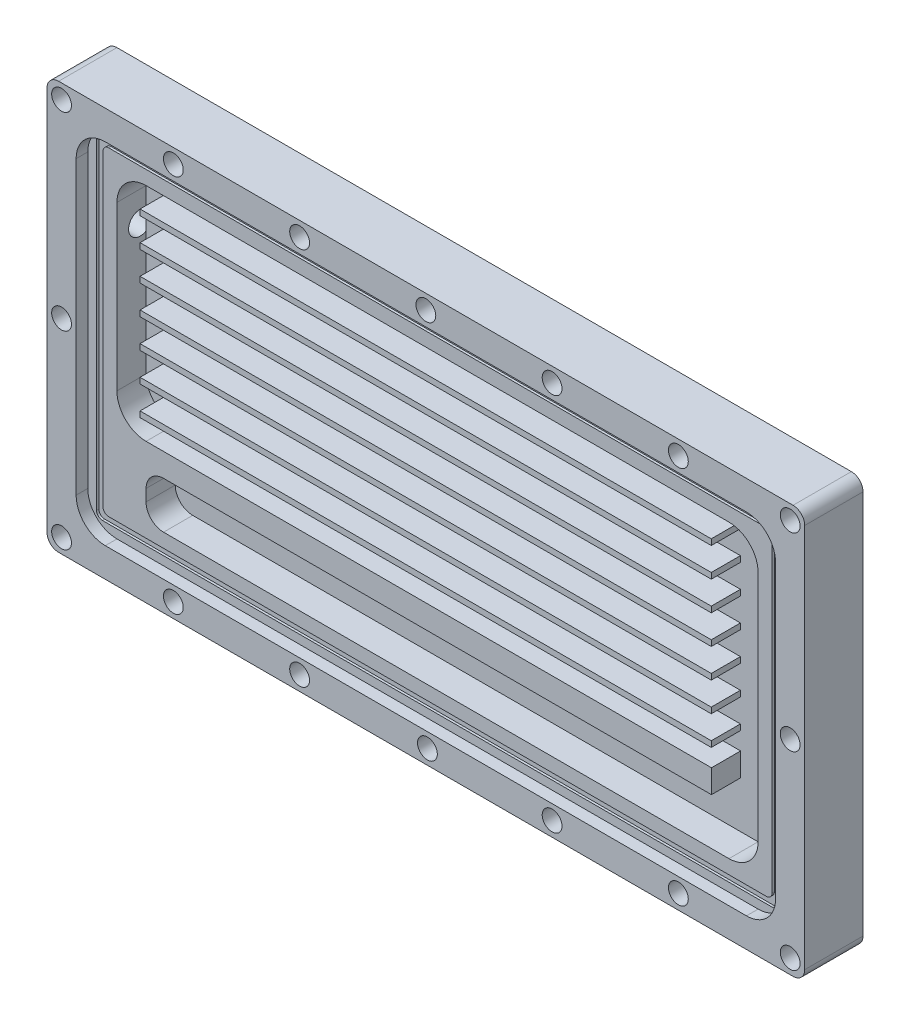
from build123d import *

# Parameters (mm, degrees)
BOSS_EXTRU_1_DEPTH      = 10
ENL_V_MAT_EXTRU_1_DEPTH = 2
ENL_V_MAT_EXTRU_3_DEPTH = 5
ESQUISSE23_W            = 98
ESQUISSE23_H            = 1
BOSS_EXTRU_2_DEPTH      = 5
ENL_V_MAT_EXTRU_4_DEPTH = 0.4
ESQUISSE19_R            = 2
ENL_V_MAT_EXTRU_5_DEPTH = 10
D_GAGEMENT_M31_D        = 3.4
D_GAGEMENT_M31_DEPTH    = 3.978536948
D_GAGEMENT_M31_TIP      = 1.021463052


with BuildPart() as part:
    # Esquisse1 → Boss.-Extru.1 (new body)
    with BuildSketch(Plane.XY):
        with BuildLine():
            Line((2, 0), (128, 0))
            ThreePointArc((128, 0), (129.414213562, 0.585786438), (130, 2))
            Line((130, 2), (130, 68))
            ThreePointArc((130, 68), (129.414213562, 69.414213562), (128, 70))
            Line((128, 70), (2, 70))
            ThreePointArc((2, 70), (0.585786438, 69.414213562), (0, 68))
            Line((0, 68), (0, 2))
            ThreePointArc((0, 2), (0.585786438, 0.585786438), (2, 0))
        make_face()
    extrude(amount=BOSS_EXTRU_1_DEPTH)

    # Esquisse18 → Enlèv. mat.-Extru.1 (cut)
    with BuildSketch(Plane.XY.offset(10)):
        with BuildLine():
            Line((10, 5), (120, 5))
            ThreePointArc((120, 5), (123.535533906, 6.464466094), (125, 10))
            Line((125, 10), (125, 60))
            ThreePointArc((125, 60), (123.535533906, 63.535533906), (120, 65))
            Line((120, 65), (10, 65))
            ThreePointArc((10, 65), (6.464466094, 63.535533906), (5, 60))
            Line((5, 60), (5, 10))
            ThreePointArc((5, 10), (6.464466094, 6.464466094), (10, 5))
        make_face()
    extrude(amount=-ENL_V_MAT_EXTRU_1_DEPTH, mode=Mode.SUBTRACT)

    # Esquisse20 → Enlèv. mat.-Extru.3 (cut)
    with BuildSketch(Plane.XY.offset(8)):
        with BuildLine():
            Line((15, 60), (115, 60))
            ThreePointArc((115, 60), (118.535533906, 58.535533906), (120, 55))
            Line((120, 55), (120, 15))
            ThreePointArc((120, 15), (118.535533906, 11.464466094), (115, 10))
            Line((115, 10), (18, 10))
            ThreePointArc((18, 10), (15.878679656, 10.878679656), (15, 13))
            Line((15, 13), (15, 15))
            ThreePointArc((15, 15), (15.878679656, 17.121320344), (18, 18))
            Line((18, 18), (112, 18))
            Line((112, 18), (112, 22))
            Line((112, 22), (15, 22))
            ThreePointArc((15, 22), (11.464466094, 23.464466094), (10, 27))
            Line((10, 27), (10, 55))
            ThreePointArc((10, 55), (11.464466094, 58.535533906), (15, 60))
        make_face()
    extrude(amount=-ENL_V_MAT_EXTRU_3_DEPTH, mode=Mode.SUBTRACT)

    # Esquisse23 → Boss.-Extru.2 (add)
    with BuildSketch(Plane.XY.offset(3)):
        with Locations((62.966066354, 55.5)):
            Rectangle(ESQUISSE23_W, ESQUISSE23_H)
        with Locations((62.966066354, 50.5)):
            Rectangle(ESQUISSE23_W, ESQUISSE23_H)
        with Locations((62.966066354, 45.5)):
            Rectangle(ESQUISSE23_W, ESQUISSE23_H)
        with Locations((62.966066354, 40.5)):
            Rectangle(ESQUISSE23_W, ESQUISSE23_H)
        with Locations((62.966066354, 35.5)):
            Rectangle(ESQUISSE23_W, ESQUISSE23_H)
        with Locations((62.966066354, 30.5)):
            Rectangle(ESQUISSE23_W, ESQUISSE23_H)
        with Locations((62.966066354, 25.5)):
            Rectangle(ESQUISSE23_W, ESQUISSE23_H)
    extrude(amount=BOSS_EXTRU_2_DEPTH)

    # Esquisse24 → Enlèv. mat.-Extru.4 (cut)
    with BuildSketch(Plane.XY.offset(8)):
        with BuildLine():
            Line((6.5, 62.5), (6.5, 7.5))
            ThreePointArc((6.5, 7.5), (6.792893219, 6.792893219), (7.5, 6.5))
            Line((7.5, 6.5), (7.967348912, 6.5))
            Line((7.967348912, 6.5), (122.5, 6.5))
            ThreePointArc((122.5, 6.5), (123.207106781, 6.792893219), (123.5, 7.5))
            Line((123.5, 7.5), (123.5, 62.5))
            ThreePointArc((123.5, 62.5), (123.207106781, 63.207106781), (122.5, 63.5))
            Line((122.5, 63.5), (7.5, 63.5))
            ThreePointArc((7.5, 63.5), (6.792893219, 63.207106781), (6.5, 62.5))
        make_face()
        with BuildLine():
            Line((8.6, 62.4), (121.4, 62.4))
            ThreePointArc((121.4, 62.4), (122.107106781, 62.107106781), (122.4, 61.4))
            Line((122.4, 61.4), (122.4, 8.6))
            ThreePointArc((122.4, 8.6), (122.107106781, 7.892893219), (121.4, 7.6))
            Line((121.4, 7.6), (8.6, 7.6))
            ThreePointArc((8.6, 7.6), (7.892893219, 7.892893219), (7.6, 8.6))
            Line((7.6, 8.6), (7.6, 61.4))
            ThreePointArc((7.6, 61.4), (7.892893219, 62.107106781), (8.6, 62.4))
        make_face(mode=Mode.SUBTRACT)
    extrude(amount=-ENL_V_MAT_EXTRU_4_DEPTH, mode=Mode.SUBTRACT)

    # Esquisse19 → Enlèv. mat.-Extru.5 (cut)
    with BuildSketch(Plane.ZY):
        with Locations((4, 50)):
            Circle(ESQUISSE19_R)
        with Locations((4, 12)):
            Circle(ESQUISSE19_R)
    extrude(amount=-ENL_V_MAT_EXTRU_5_DEPTH, mode=Mode.SUBTRACT)

    # Dégagement M31
    with Locations(Plane.XY.offset(10)):
        with Locations((127.5, 67.5), (108.32, 67.5), (86.66, 67.5), (65, 67.5), (43.34, 67.5), (21.68, 67.5), (2.5, 67.5), (2.5, 35), (2.5, 2.5), (21.68, 2.5), (43.34, 2.5), (65.266790711, 2.5), (86.66, 2.5), (108.32, 2.5), (127.5, 2.5), (127.5, 35)):
            Hole(D_GAGEMENT_M31_D / 2, depth=D_GAGEMENT_M31_DEPTH)
            with Locations((0, 0, -(D_GAGEMENT_M31_DEPTH + D_GAGEMENT_M31_TIP / 2))):  # 118° drill point
                Cone(0, D_GAGEMENT_M31_D / 2, D_GAGEMENT_M31_TIP, mode=Mode.SUBTRACT)


solid = part.part
